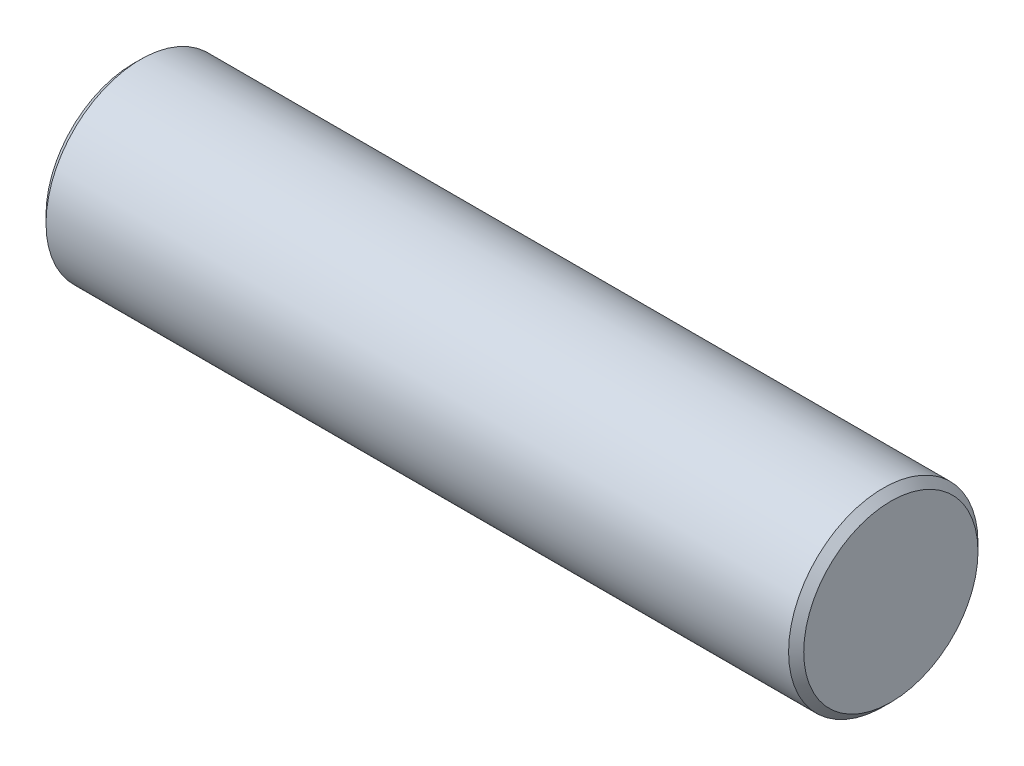
from build123d import *

# Parameters (mm, degrees)
XSECTION_R      = 3.175
EXTRUSION_DEPTH = 12.7
CHAMFER1_SIZE   = 0.254


with BuildPart() as part:
    # xsection → extrusion (new body, symmetric)
    with BuildSketch(Plane(origin=(0, 0, 0), x_dir=(0, 0, -1), z_dir=(1, 0, 0))):
        Circle(XSECTION_R)
    extrude(amount=EXTRUSION_DEPTH, both=True)

    # Chamfer1
    chamfer1_edges = [part.edges().sort_by_distance(p)[0] for p in [
        (-12.7, 0, 3.175),
        (12.7, 0, 3.175),
    ]]
    chamfer(chamfer1_edges, length=CHAMFER1_SIZE)


solid = part.part
